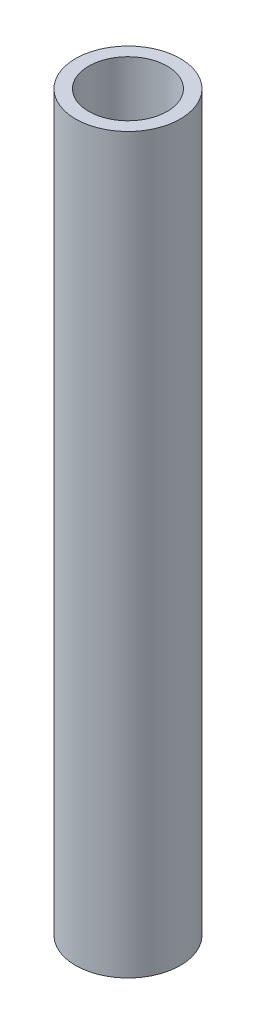
from build123d import *

# Parameters (mm, degrees)
SKETCH1_R           = 12.7
SKETCH1_R_2         = 9.525
BOSS_EXTRUDE2_DEPTH = 177.8


with BuildPart() as part:
    # Sketch1 → Boss-Extrude2 (new body)
    with BuildSketch(Plane(origin=(0, 0, 0), x_dir=(1, 0, 0), z_dir=(0, 1, 0))):
        Circle(SKETCH1_R)
        Circle(SKETCH1_R_2, mode=Mode.SUBTRACT)
    extrude(amount=BOSS_EXTRUDE2_DEPTH)


solid = part.part
